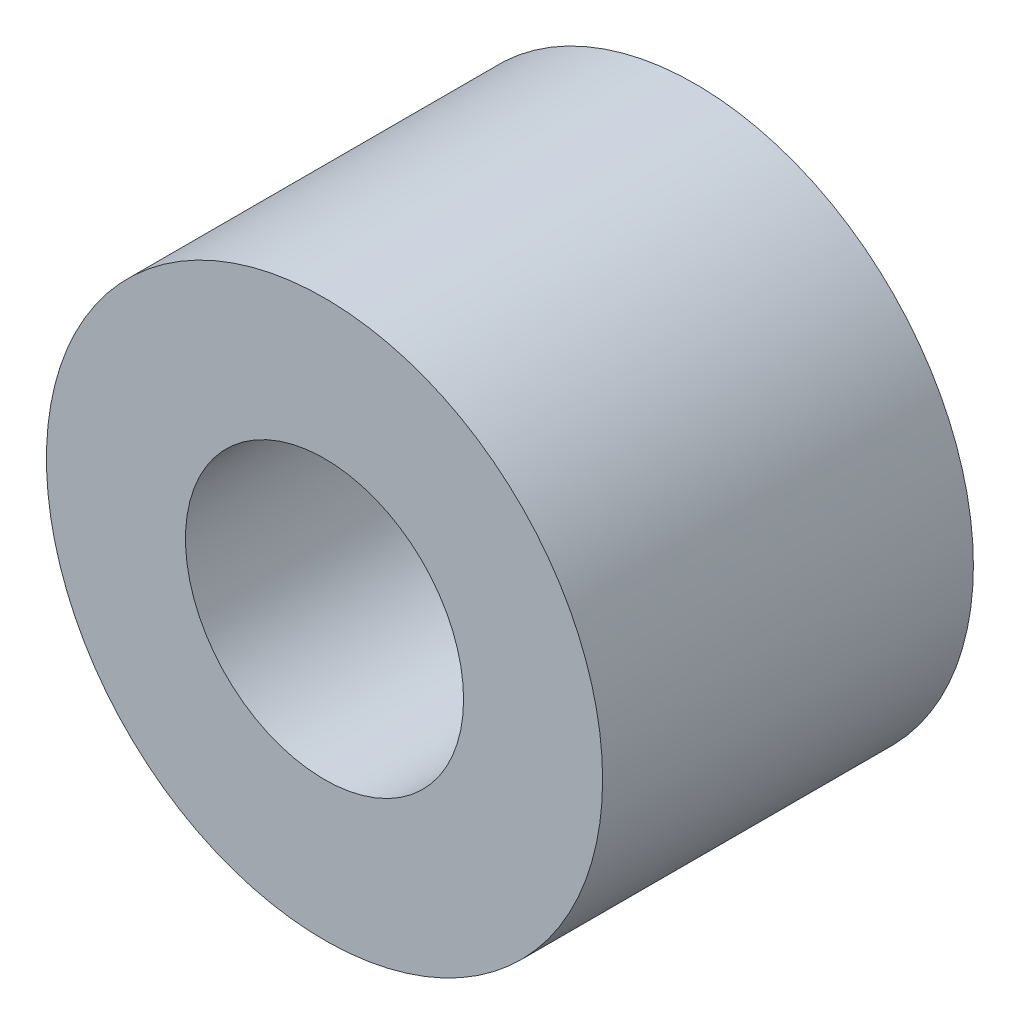
from build123d import *

# Parameters (mm, degrees)
SKETCH1_R           = 3
SKETCH1_R_2         = 1.5
BOSS_EXTRUDE1_DEPTH = 4


with BuildPart() as part:
    # Sketch1 → Boss-Extrude1 (new body)
    with BuildSketch(Plane.XY):
        with Locations((2.999999138, 3.000000057)):
            Circle(SKETCH1_R)
        with Locations((2.999999138, 3.000000057)):
            Circle(SKETCH1_R_2, mode=Mode.SUBTRACT)
    extrude(amount=BOSS_EXTRUDE1_DEPTH)


solid = part.part
